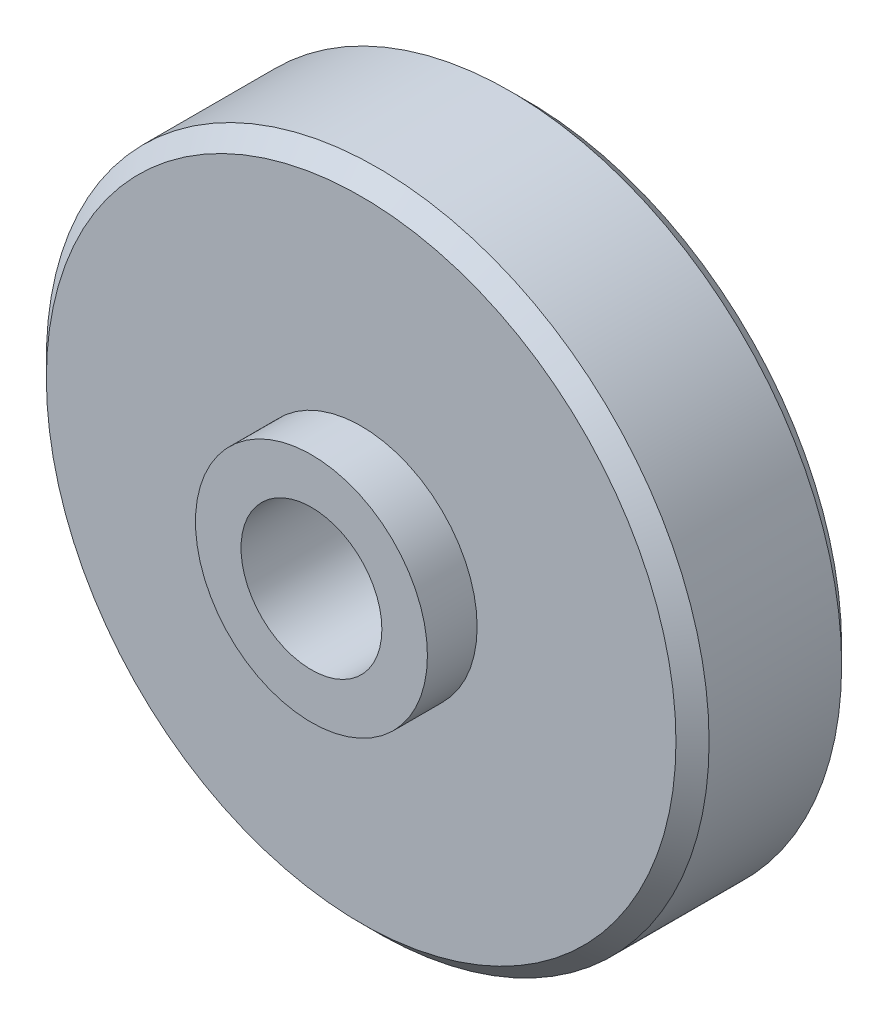
from build123d import *

# Parameters (mm, degrees)
ESQUISSE1_R        = 20
BOSS_EXTRU_1_DEPTH = 10
CHANFREIN1_SIZE    = 1
ESQUISSE2_R        = 7
BOSS_EXTRU_2_DEPTH = 3
TROU_TARAUD_M101_D = 8.5


with BuildPart() as part:
    # Esquisse1 → Boss.-Extru.1 (new body)
    with BuildSketch(Plane.XY):
        Circle(ESQUISSE1_R)
    extrude(amount=BOSS_EXTRU_1_DEPTH)

    # Chanfrein1
    chanfrein1_edges = [part.edges().sort_by_distance(p)[0] for p in [
        (-20, 0, 0),
        (-20, 0, 10),
    ]]
    chamfer(chanfrein1_edges, length=CHANFREIN1_SIZE)

    # Esquisse2 → Boss.-Extru.2 (add)
    with BuildSketch(Plane.XY.offset(10)):
        Circle(ESQUISSE2_R)
    extrude(amount=BOSS_EXTRU_2_DEPTH)

    # Trou taraudé M101 (through all)
    with Locations(Plane.XY.offset(13)):
        with Locations((0, 0)):
            Hole(TROU_TARAUD_M101_D / 2)


solid = part.part
